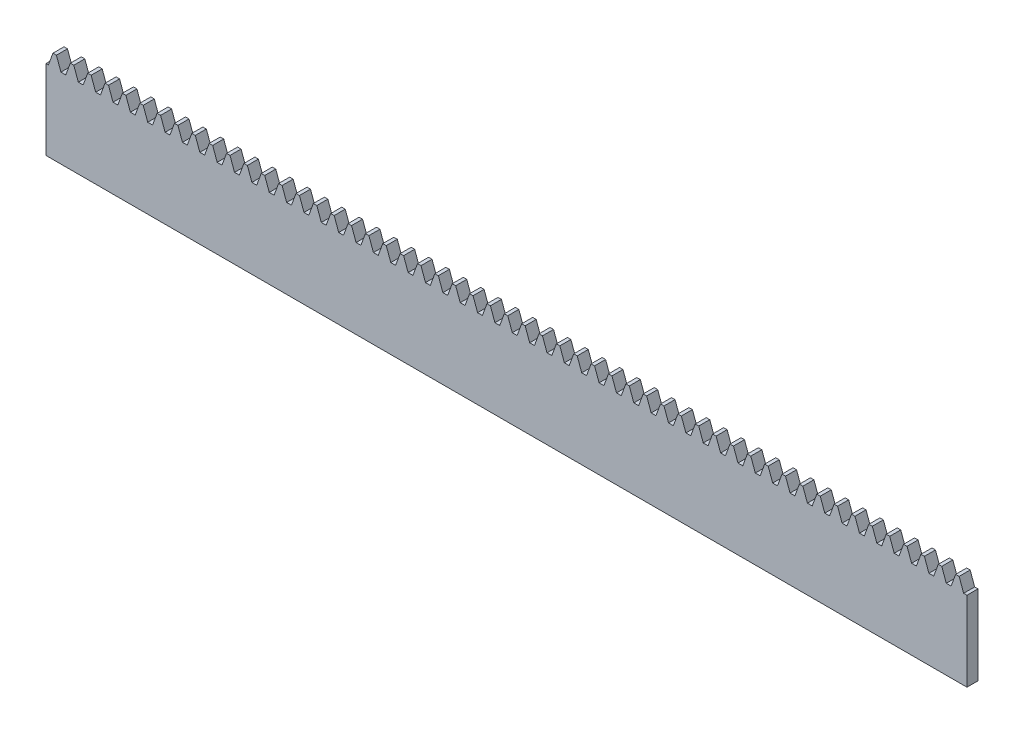
from build123d import *

# Parameters (mm, degrees)
BLANKSKE_W        = 250
BLANKSKE_H        = 25
BLANK_DEPTH       = 3
TOOTHCUTSIM_DEPTH = 252.264800559
TEETHCUTS_COUNT   = 54
TEETHCUTS_PITCH   = 4.712388975


with BuildPart() as part:
    # BlankSke → Blank (new body)
    with BuildSketch(Plane.XY):
        with Locations((125, 12.5)):
            Rectangle(BLANKSKE_W, BLANKSKE_H)
    extrude(amount=-BLANK_DEPTH)

    # TooCutSkeSim → ToothCutSim (cut, through all)
    with BuildSketch(Plane.XY):
        Polygon((0.654653055, 21.625), (-0.654653055, 21.625), (-1.975501035, 25.254), (1.975501035, 25.254), align=None)
    toothcutsim = extrude(amount=-TOOTHCUTSIM_DEPTH, mode=Mode.SUBTRACT)

    # TeethCuts: ToothCutSim ×54
    with Locations(*[(i * TEETHCUTS_PITCH, 0, 0) for i in range(1, TEETHCUTS_COUNT)]):
        add(toothcutsim, mode=Mode.SUBTRACT)


solid = part.part
